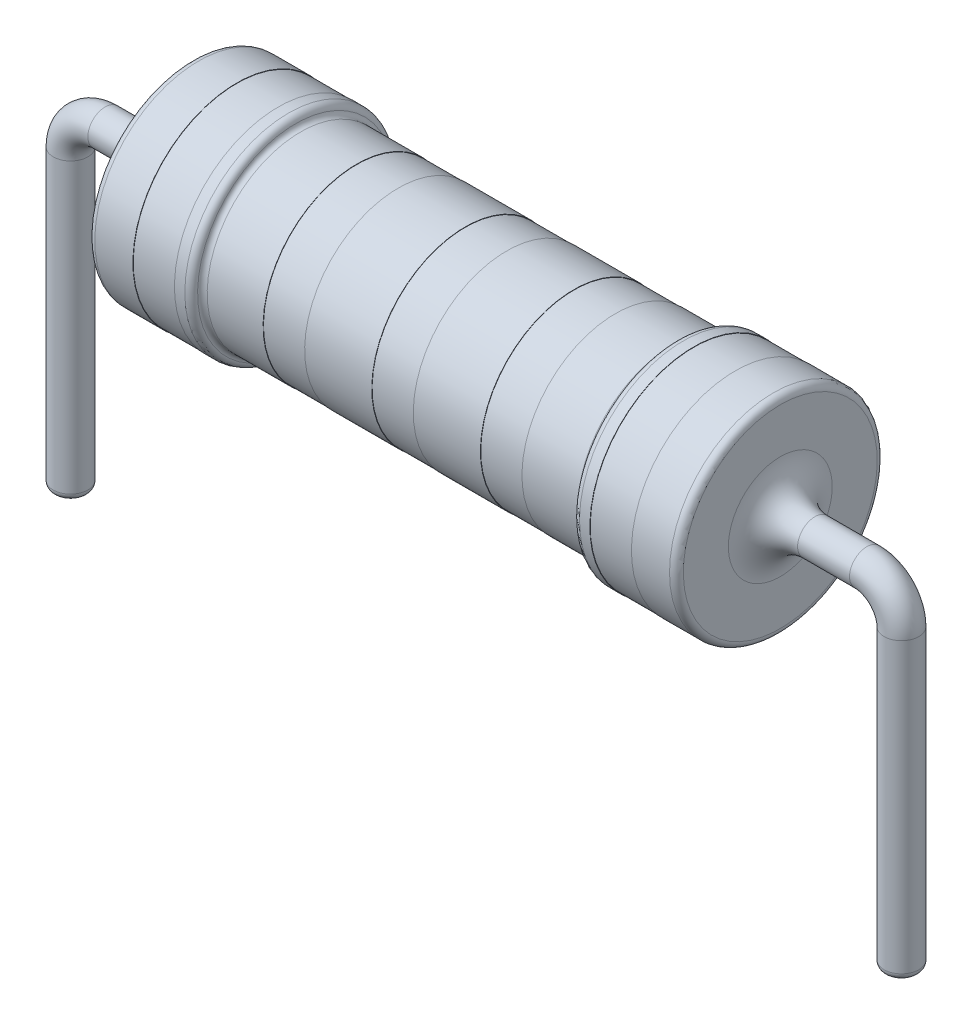
from build123d import *

# Parameters (mm, degrees)
SKETCH2_R = 0.5
FILLET1_R = 0.2
FILLET2_R = 0.15
FILLET5_R = 1
FILLET6_R = 0.2


with BuildPart() as part:
    # Sketch1 → Revolve1 (revolve)
    with BuildSketch(Plane.XY):
        Polygon((-8.5, 0), (8.5, 0), (8.5, -3), (7.2, -3), (7.2, -2.99), (6, -2.99), (6, -3), (5.5, -3), (5.5, -2.7), (3.738022236, -2.7), (3.738022236, -2.69), (2.538022236, -2.69), (2.538022236, -2.7), (0.6, -2.7), (0.6, -2.69), (-0.6, -2.69), (-0.6, -2.7), (-2.538022236, -2.7), (-2.538022236, -2.69), (-3.738022236, -2.69), (-3.738022236, -2.7), (-5.5, -2.7), (-5.5, -3), (-6, -3), (-6, -2.99), (-7.2, -2.99), (-7.2, -3), (-8.5, -3), align=None)
    revolve(axis=Axis((-8.5, 0, 0), (1, 0, 0)))

    # Sweep1: sweep along a curve in space
    with BuildLine() as sweep1_path:
        Line((8.5, 0, 0), (11, 0, 0))
        ThreePointArc((12, -1, 0), (11.707106781, -0.292893219, 0), (11, 0, 0))
        Line((12, -1, 0), (12, -9.532986199, 0))
    # Sketch2 → Sweep1 (sweep)
    with BuildSketch(Plane(origin=(8.5, 0, 0), x_dir=(0, 0, -1), z_dir=(1, 0, 0))):
        Circle(SKETCH2_R)
    sweep1 = sweep(path=sweep1_path.line)

    # Mirror1: Sweep1 across plane
    add(sweep1.mirror(Plane(origin=(0, 0, 0), x_dir=(0, 0, 1), z_dir=(1, 0, 0))))

    # Fillet1
    fillet1_edges = [part.edges().sort_by_distance(p)[0] for p in [
        (-8.5, 3, 0),
        (-5.5, 3, 0),
        (5.5, 3, 0),
        (8.5, 3, 0),
    ]]
    fillet(fillet1_edges, radius=FILLET1_R)

    # Fillet2
    fillet2_edges = [part.edges().sort_by_distance(p)[0] for p in [
        (-5.5, 2.7, 0),
        (5.5, 2.7, 0),
    ]]
    fillet(fillet2_edges, radius=FILLET2_R)

    # Fillet5
    fillet5_edges = [part.edges().sort_by_distance(p)[0] for p in [
        (8.5, 0, 0.5),
        (-8.5, 0, 0.5),
    ]]
    fillet(fillet5_edges, radius=FILLET5_R)

    # Fillet6
    fillet6_edges = [part.edges().sort_by_distance(p)[0] for p in [
        (12, -9.532986199, 0.5),
        (-12, -9.532986199, 0.5),
    ]]
    fillet(fillet6_edges, radius=FILLET6_R)


solid = part.part
